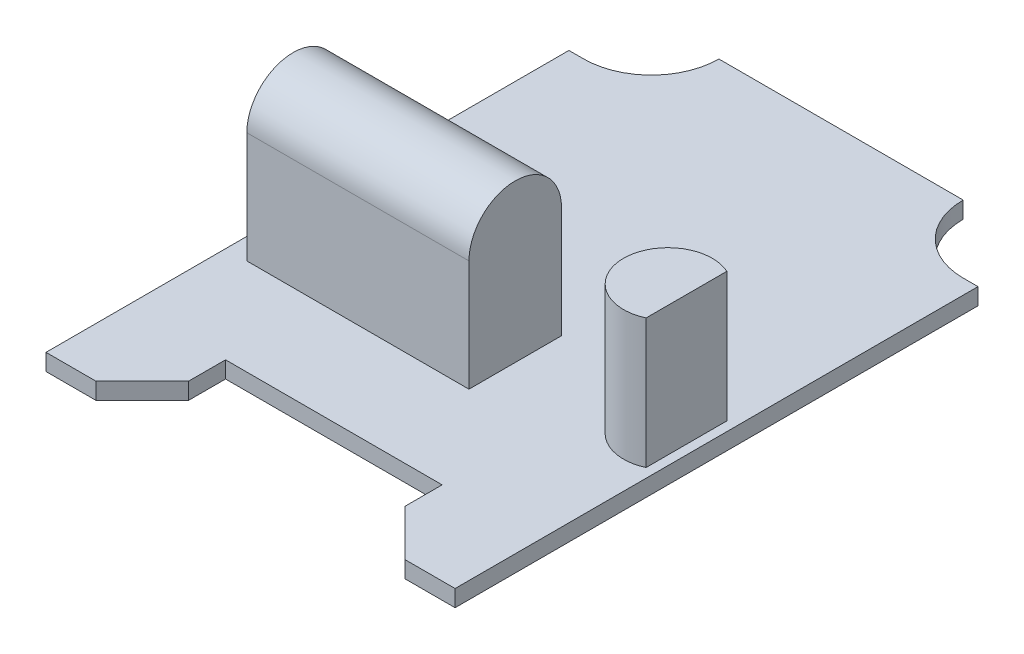
from build123d import *

# Parameters (mm, degrees)
BOSS_EXTRUDE1_DEPTH = 0.9
BOSS_EXTRUDE4_DEPTH = 12
BOSS_EXTRUDE5_DEPTH = 7


with BuildPart() as part:
    # Sketch1 → Boss-Extrude1 (new body)
    with BuildSketch(Plane(origin=(0, 0, 0), x_dir=(1, 0, 0), z_dir=(0, 1, 0))):
        with BuildLine():
            Line((-11.05, 0), (-11.05, 28.25))
            Line((-11.05, 28.25), (-10.25, 28.25))
            ThreePointArc((-10.25, 28.25), (-7.669060249, 29.319060249), (-6.6, 31.9))
            Line((-6.6, 31.9), (6.6, 31.9))
            ThreePointArc((6.6, 31.9), (7.669060249, 29.319060249), (10.25, 28.25))
            Line((10.25, 28.25), (11.05, 28.25))
            Line((11.05, 28.25), (11.05, 0))
            Line((11.05, 0), (8.35, 0))
            Line((8.35, 0), (5.85, 2.5))
            Line((5.85, 2.5), (5.85, 4.5))
            Line((5.85, 4.5), (-5.85, 4.5))
            Line((-5.85, 4.5), (-5.85, 2.5))
            Line((-5.85, 2.5), (-8.35, 0))
            Line((-8.35, 0), (-11.05, 0))
        make_face()
    extrude(amount=BOSS_EXTRUDE1_DEPTH)

    # Sketch4 → Boss-Extrude4 (add)
    with BuildSketch(Plane.ZY.offset(9.9)):
        with BuildLine():
            Line((-9.7, 0.9), (-9.7, 6.9))
            ThreePointArc((-9.7, 6.9), (-12.2, 9.4), (-14.7, 6.9))
            Line((-14.7, 6.9), (-14.7, 0.9))
            Line((-14.7, 0.9), (-9.7, 0.9))
        make_face()
    extrude(amount=-BOSS_EXTRUDE4_DEPTH)

    # Sketch5 → Boss-Extrude5 (add)
    with BuildSketch(Plane(origin=(0, 0.9, 0), x_dir=(1, 0, 0), z_dir=(0, 1, 0))):
        with BuildLine():
            Line((10.55, 15.181742423), (10.55, 10.818257577))
            ThreePointArc((10.55, 10.818257577), (7.15, 13), (10.55, 15.181742423))
        make_face()
    extrude(amount=BOSS_EXTRUDE5_DEPTH)


solid = part.part
